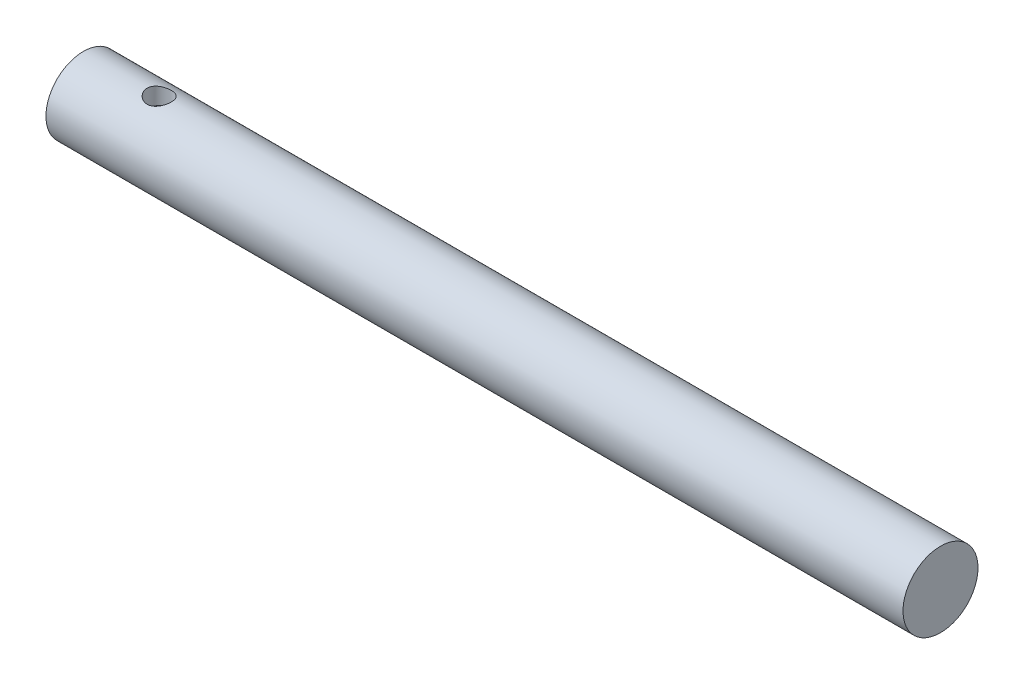
from build123d import *

# Parameters (mm, degrees)
SKETCH1_R           = 3.1115
BOSS_EXTRUDE1_DEPTH = 71.12
CUT_EXTRUDE1_DEPTH  = 12
SKETCH3_R           = 1
CUT_EXTRUDE2_DEPTH  = 2.54


with BuildPart() as part:
    # Sketch1 → Boss-Extrude1 (new body)
    with BuildSketch(Plane(origin=(0, 0, 0), x_dir=(0, 0, -1), z_dir=(1, 0, 0))):
        Circle(SKETCH1_R)
    extrude(amount=BOSS_EXTRUDE1_DEPTH)

    # Sketch2 → Cut-Extrude1 (cut)
    with BuildSketch(Plane.ZY):
        with BuildLine():
            Line((-1.151593115, 1.651), (1.151593115, 1.651))
            ThreePointArc((1.151593115, 1.651), (0, -2.01295), (-1.151593115, 1.651))
        make_face()
    extrude(amount=-CUT_EXTRUDE1_DEPTH, mode=Mode.SUBTRACT)

    # Sketch3 → Cut-Extrude2 (cut)
    with BuildSketch(Plane.XZ.offset(-1.651)):
        with Locations((6.288563634, 0)):
            Circle(SKETCH3_R)
    extrude(amount=-CUT_EXTRUDE2_DEPTH, mode=Mode.SUBTRACT)


solid = part.part
